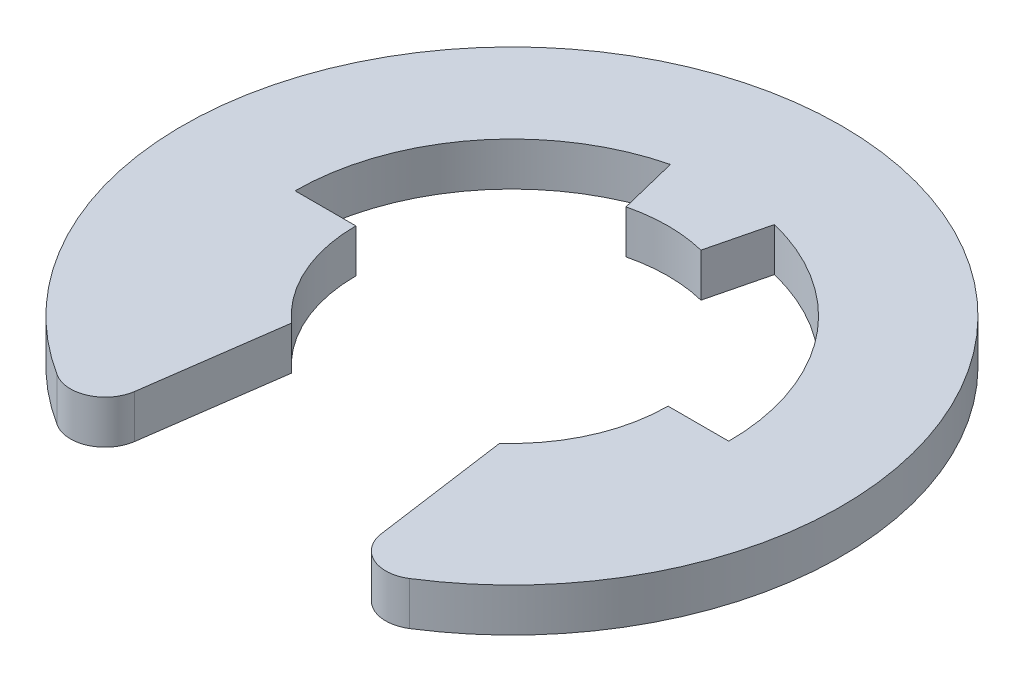
from build123d import *

# Parameters (mm, degrees)
BOSS_EXTRUDE1_DEPTH = 0.3175
FILLET1_R           = 0.508


with BuildPart() as part:
    # Sketch2 → Boss-Extrude1 (new body, symmetric)
    with BuildSketch(Plane(origin=(0, 0, 0), x_dir=(1, 0, 0), z_dir=(0, 1, 0))):
        with BuildLine():
            Line((-3.175, 0), (-2.286, 0))
            ThreePointArc((-2.286, 0), (-2.086822944, -0.933255592), (-1.524, -1.703883799))
            Line((-1.524, -1.703883799), (-1.905, -4.434100924))
            ThreePointArc((-1.905, -4.434100924), (0, 4.826), (1.905, -4.434100924))
            Line((1.905, -4.434100924), (1.524, -1.703883799))
            ThreePointArc((1.524, -1.703883799), (2.086822944, -0.933255592), (2.286, 0))
            Line((2.286, 0), (3.175, 0))
            ThreePointArc((3.175, 0), (2.4999975, 1.957201446), (0.762, 3.082203919))
            Line((0.762, 3.082203919), (0.54864, 2.219186822))
            ThreePointArc((0.54864, 2.219186822), (0, 2.286), (-0.54864, 2.219186822))
            Line((-0.54864, 2.219186822), (-0.762, 3.082203919))
            ThreePointArc((-0.762, 3.082203919), (-2.4999975, 1.957201446), (-3.175, 0))
        make_face()
    extrude(amount=BOSS_EXTRUDE1_DEPTH, both=True)

    # Fillet1
    fillet1_edges = [part.edges().sort_by_distance(p)[0] for p in [
        (-1.905, 0, 4.434100924),
        (1.905, 0, 4.434100924),
    ]]
    fillet(fillet1_edges, radius=FILLET1_R)


solid = part.part
